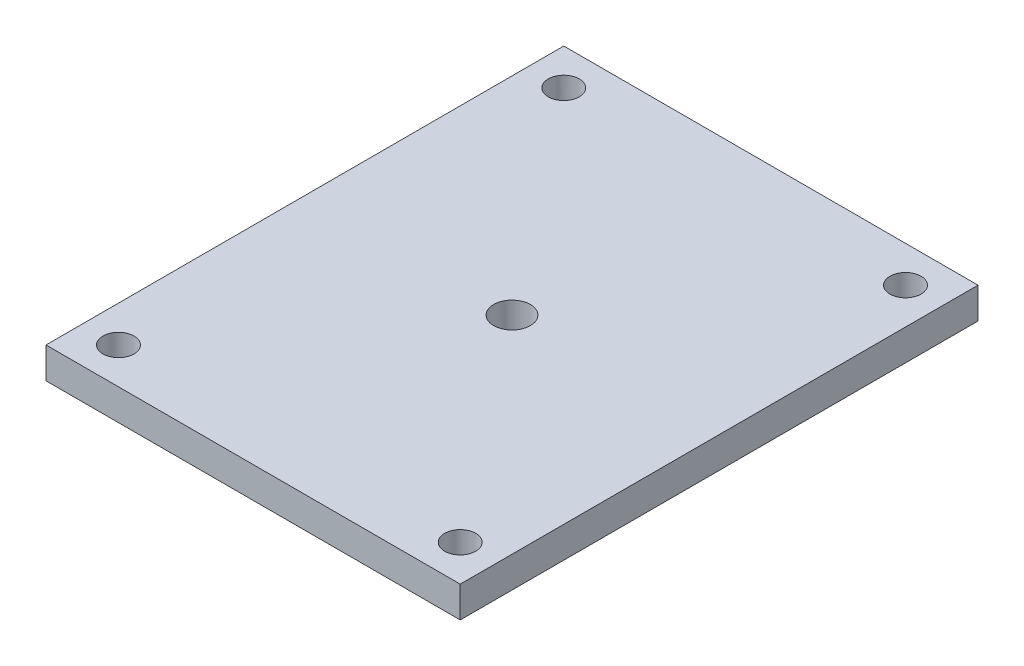
from build123d import *

# Parameters (mm, degrees)
CROQUIS2_W              = 508
CROQUIS2_H              = 635
SALIENTE_EXTRUIR2_DEPTH = 38.1
CROQUIS3_R              = 19.05
CORTAR_EXTRUIR1_DEPTH   = 38.1
CROQUIS4_R              = 22.5
CORTAR_EXTRUIR2_DEPTH   = 38.1


with BuildPart() as part:
    # Croquis2 → Saliente-Extruir2 (new body)
    with BuildSketch(Plane(origin=(0, 0, 0), x_dir=(1, 0, 0), z_dir=(0, 1, 0))):
        Rectangle(CROQUIS2_W, CROQUIS2_H)
    extrude(amount=SALIENTE_EXTRUIR2_DEPTH)

    # Croquis3 → Cortar-Extruir1 (cut)
    with BuildSketch(Plane(origin=(0, 38.1, 0), x_dir=(1, 0, 0), z_dir=(0, 1, 0))):
        with Locations((-209.55, 273.05)):
            Circle(CROQUIS3_R)
        with Locations((209.55, 273.05)):
            Circle(CROQUIS3_R)
        with Locations((209.55, -273.05)):
            Circle(CROQUIS3_R)
        with Locations((-209.55, -273.05)):
            Circle(CROQUIS3_R)
    extrude(amount=-CORTAR_EXTRUIR1_DEPTH, mode=Mode.SUBTRACT)

    # Croquis4 → Cortar-Extruir2 (cut)
    with BuildSketch(Plane(origin=(0, 38.1, 0), x_dir=(1, 0, 0), z_dir=(0, 1, 0))):
        Circle(CROQUIS4_R)
    extrude(amount=-CORTAR_EXTRUIR2_DEPTH, mode=Mode.SUBTRACT)


solid = part.part
